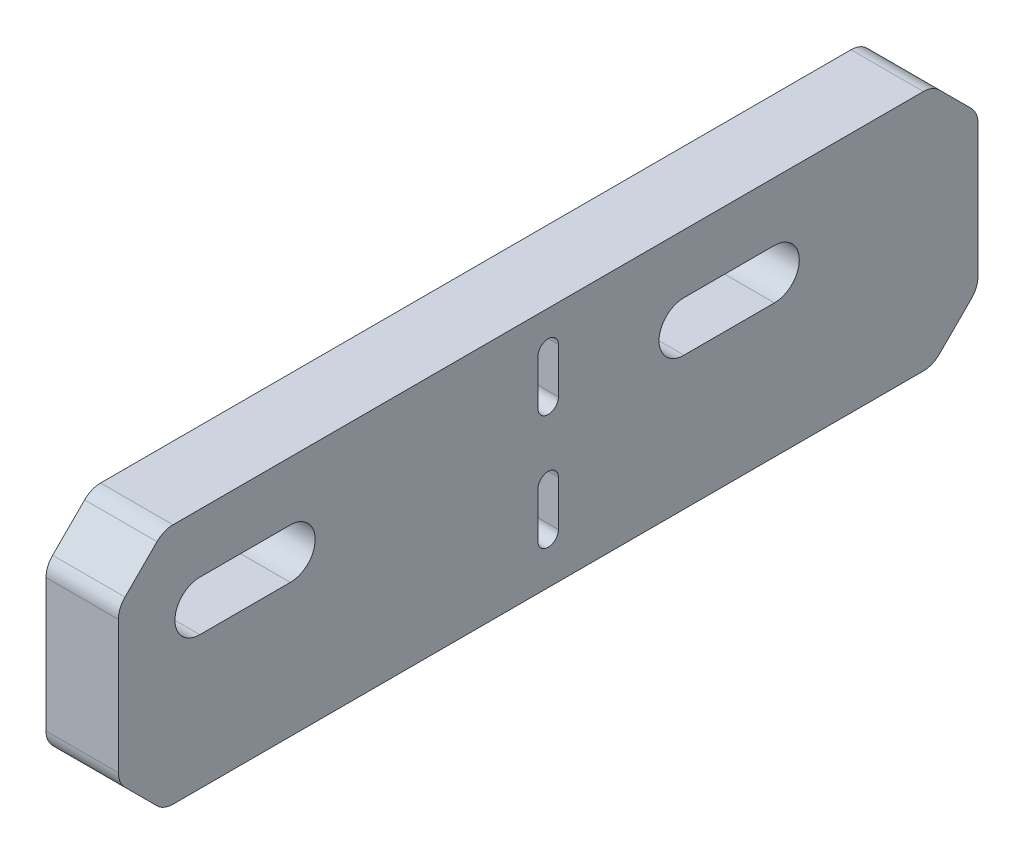
from build123d import *

# Parameters (mm, degrees)
SKETCH1_W             = 80
SKETCH1_H             = 21.75
MAIN_DEPTH            = 8
M5_CLEARANCE_HOLE1_D  = 5.5
F_2_CLEARANCE_HOLE1_D = 2.2606
SPACER_DEPTH          = 8
CUT_EXTRUDE3_DEPTH    = 10
CHAMFER1_SIZE         = 5
FILLET1_R             = 2.5


with BuildPart() as part:
    # Sketch1 → Main (new body)
    with BuildSketch(Plane(origin=(0, 0, 0), x_dir=(0, 0, -1), z_dir=(1, 0, 0))):
        Rectangle(SKETCH1_W, SKETCH1_H)
    extrude(amount=MAIN_DEPTH)

    # M5 Clearance Hole1 (through all)
    with Locations(Plane.ZY):
        with Locations((-20, 1.625), (33.5, 1.625)):
            Hole(M5_CLEARANCE_HOLE1_D / 2)

    # #2 Clearance Hole1 (through all)
    with Locations(Plane.ZY):
        with Locations((0, -8.375), (0, 4.325)):
            Hole(F_2_CLEARANCE_HOLE1_D / 2)

    # Sketch13 → Spacer (add)
    with BuildSketch(Plane.ZY):
        Polygon((40, 10.875), (47.5, 10.875), (47.5, -15.875), (-47.5, -15.875), (-47.5, 10.875), (-40, 10.875), (-40, -10.875), (40, -10.875), align=None)
    extrude(amount=-SPACER_DEPTH)

    # Sketch14 → Cut-Extrude3 (cut)
    with BuildSketch(Plane.ZY):
        with BuildLine():
            Line((38.5, -1.125), (28.5, -1.125))
            ThreePointArc((28.5, -1.125), (25.75, 1.625), (28.5, 4.375))
            Line((28.5, 4.375), (38.5, 4.375))
            ThreePointArc((38.5, 4.375), (41.25, 1.625), (38.5, -1.125))
        make_face()
        with BuildLine():
            Line((-15, -1.125), (-25, -1.125))
            ThreePointArc((-25, -1.125), (-27.75, 1.625), (-25, 4.375))
            Line((-25, 4.375), (-15, 4.375))
            ThreePointArc((-15, 4.375), (-12.25, 1.625), (-15, -1.125))
        make_face()
        with BuildLine():
            Line((1.1303, -5.875), (1.1303, -10.875))
            ThreePointArc((1.1303, -10.875), (0, -12.0053), (-1.1303, -10.875))
            Line((-1.1303, -10.875), (-1.1303, -5.875))
            ThreePointArc((-1.1303, -5.875), (0, -4.7447), (1.1303, -5.875))
        make_face()
        with BuildLine():
            Line((1.1303, 6.825), (1.1303, 1.825))
            ThreePointArc((1.1303, 1.825), (0, 0.6947), (-1.1303, 1.825))
            Line((-1.1303, 1.825), (-1.1303, 6.825))
            ThreePointArc((-1.1303, 6.825), (0, 7.9553), (1.1303, 6.825))
        make_face()
    extrude(amount=-CUT_EXTRUDE3_DEPTH, mode=Mode.SUBTRACT)

    # Chamfer1
    chamfer1_edges = [part.edges().sort_by_distance(p)[0] for p in [
        (4, 10.875, -47.5),
        (4, 10.875, 47.5),
        (4, -15.875, 47.5),
        (4, -15.875, -47.5),
    ]]
    chamfer(chamfer1_edges, length=CHAMFER1_SIZE)

    # Fillet1
    fillet1_edges = [part.edges().sort_by_distance(p)[0] for p in [
        (4, 10.875, 42.5),
        (4, 10.875, -42.5),
        (4, -10.875, -47.5),
        (4, 5.875, -47.5),
        (4, -15.875, 42.5),
        (4, -15.875, -42.5),
        (4, -10.875, 47.5),
        (4, 5.875, 47.5),
    ]]
    fillet(fillet1_edges, radius=FILLET1_R)


solid = part.part
